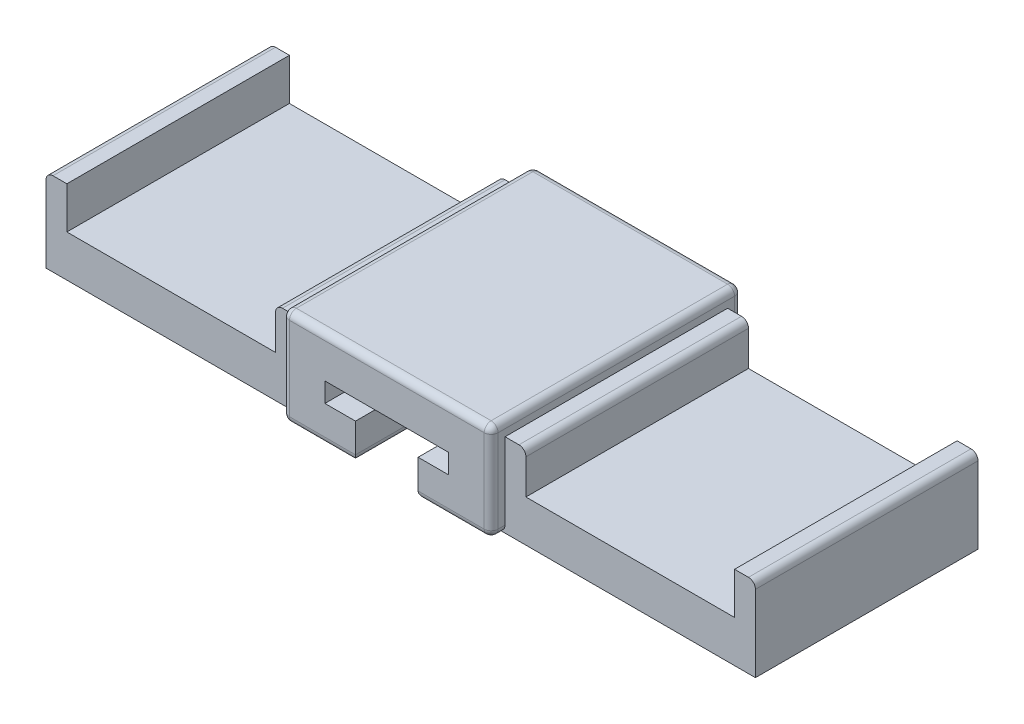
from build123d import *

# Parameters (mm, degrees)
SKETCH1_W           = 15
SKETCH1_H           = 18
BOSS_EXTRUDE1_DEPTH = 7
CUT_EXTRUDE1_DEPTH  = 16.2
SKETCH9_W           = 16
SKETCH9_H           = 6
BOSS_EXTRUDE2_DEPTH = 18
SKETCH13_W          = 16
SKETCH13_H          = 6
BOSS_EXTRUDE3_DEPTH = 18
SKETCH14_W          = 15
SKETCH14_H          = 3
CUT_EXTRUDE5_DEPTH  = 32.55
FILLET1_R           = 0.5


with BuildPart() as part:
    # Sketch1 → Boss-Extrude1 (new body)
    with BuildSketch(Plane(origin=(0, 0, 0), x_dir=(1, 0, 0), z_dir=(0, 1, 0))):
        Rectangle(SKETCH1_W, SKETCH1_H)
    extrude(amount=BOSS_EXTRUDE1_DEPTH)

    # Sketch2 → Cut-Extrude1 (cut)
    with BuildSketch(Plane.XY.offset(9)):
        Polygon((-2.25, 2.6), (-2.25, 0), (2.25, 0), (2.25, 2.6), (4.45, 2.6), (4.45, 4), (-4.45, 4), (-4.45, 2.6), align=None)
    extrude(amount=-CUT_EXTRUDE1_DEPTH, mode=Mode.SUBTRACT)

    # Sketch9 → Boss-Extrude2 (add)
    with BuildSketch(Plane.ZY.offset(7.5)):
        with Locations((0, 3)):
            Rectangle(SKETCH9_W, SKETCH9_H)
    extrude(amount=BOSS_EXTRUDE2_DEPTH)

    # Sketch13 → Boss-Extrude3 (add)
    with BuildSketch(Plane(origin=(7.5, 0, 0), x_dir=(0, 0, -1), z_dir=(1, 0, 0))):
        with Locations((0, 3)):
            Rectangle(SKETCH13_W, SKETCH13_H)
    extrude(amount=BOSS_EXTRUDE3_DEPTH)

    # Sketch14 → Cut-Extrude5 (cut)
    with BuildSketch(Plane.XY.offset(9)):
        with Locations((16.5, 4.5)):
            Rectangle(SKETCH14_W, SKETCH14_H)
        with Locations((-16.5, 4.5)):
            Rectangle(SKETCH14_W, SKETCH14_H)
    extrude(amount=-CUT_EXTRUDE5_DEPTH, mode=Mode.SUBTRACT)

    # Fillet1
    fillet1_edges = [part.edges().sort_by_distance(p)[0] for p in [
        (-7.5, 7, 0),
        (4.875, 0, 9),
        (0, 7, 9),
        (-2.25, 0, 0.9),
        (2.25, 0, 0.9),
        (-7.5, 0, 8.5),
        (-25.5, 6, 0),
        (7.5, 7, 0),
        (-4.875, 0, 9),
        (-7.5, 0, -8.5),
        (0, 0, -9),
        (7.5, 0, -8.5),
        (7.5, 0, 8.5),
        (25.5, 6, 0),
        (7.5, 3.5, 9),
        (-7.5, 3.5, 9),
        (-7.5, 3.5, -9),
        (7.5, 3.5, -9),
        (9, 6, 0),
        (0, 7, -9),
        (-9, 6, 0),
    ]]
    fillet(fillet1_edges, radius=FILLET1_R)


solid = part.part
